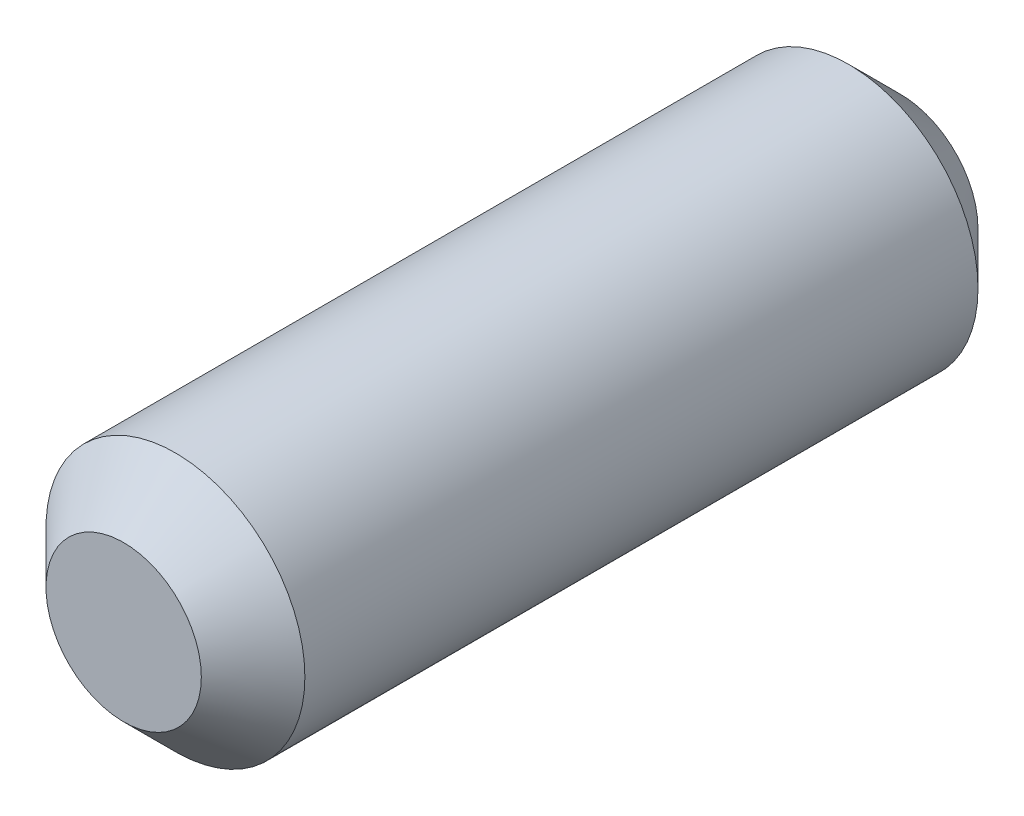
from build123d import *

# Parameters (mm, degrees)
SKETCH1_R           = 6.35
BOSS_EXTRUDE1_DEPTH = 38.1
CHAMFER1_SIZE       = 2.54
CHAMFER2_SIZE       = 2.54


with BuildPart() as part:
    # Sketch1 → Boss-Extrude1 (new body)
    with BuildSketch(Plane.XY):
        Circle(SKETCH1_R)
    extrude(amount=BOSS_EXTRUDE1_DEPTH)

    # Chamfer1
    chamfer1_edges = [part.edges().sort_by_distance(p)[0] for p in [
        (-6.35, 0, 38.1),
    ]]
    chamfer(chamfer1_edges, length=CHAMFER1_SIZE)

    # Chamfer2
    chamfer2_edges = [part.edges().sort_by_distance(p)[0] for p in [
        (-6.35, 0, 0),
    ]]
    chamfer(chamfer2_edges, length=CHAMFER2_SIZE)


solid = part.part
